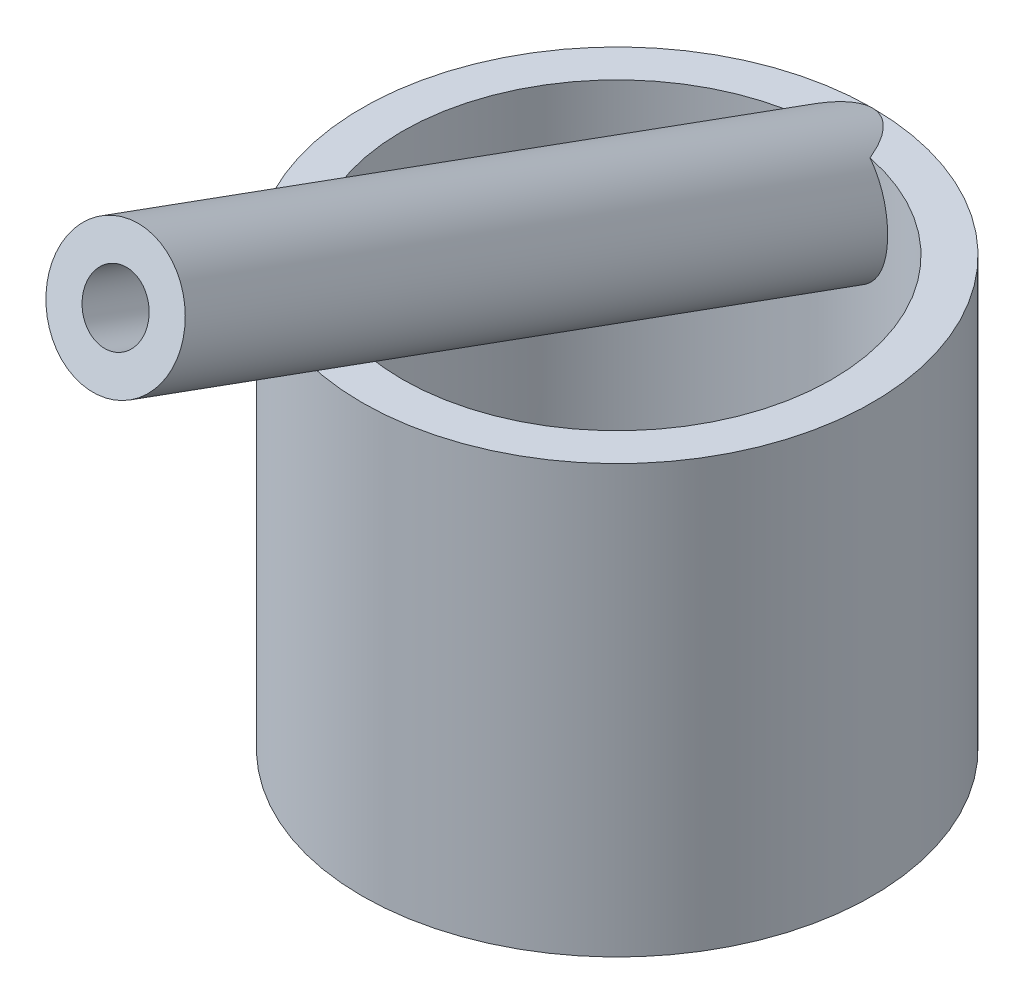
from build123d import *

# Parameters (mm, degrees)
SKETCH1_R           = 13.2715
SKETCH1_R_2         = 11.176
BOSS_EXTRUDE1_DEPTH = 22.225
SKETCH2_R           = 3.429
SKETCH2_R_2         = 1.651
BOSS_EXTRUDE2_DEPTH = 40.64


with BuildPart() as part:
    # Sketch1 → Boss-Extrude1 (new body)
    with BuildSketch(Plane(origin=(0, 0, 0), x_dir=(1, 0, 0), z_dir=(0, 1, 0))):
        Circle(SKETCH1_R)
        Circle(SKETCH1_R_2, mode=Mode.SUBTRACT)
    extrude(amount=BOSS_EXTRUDE1_DEPTH)

    # Sketch2 → Boss-Extrude2 (add)
    with BuildSketch(Plane(origin=(0, -1.665546755, -4.576052101), x_dir=(-1, 0, 0), z_dir=(0, -0.3420201433256661, -0.9396926207859093))):
        with Locations((0, 21.994788829)):
            Circle(SKETCH2_R)
        with Locations((0, 21.994788829)):
            Circle(SKETCH2_R_2, mode=Mode.SUBTRACT)
    extrude(amount=-BOSS_EXTRUDE2_DEPTH)


solid = part.part
